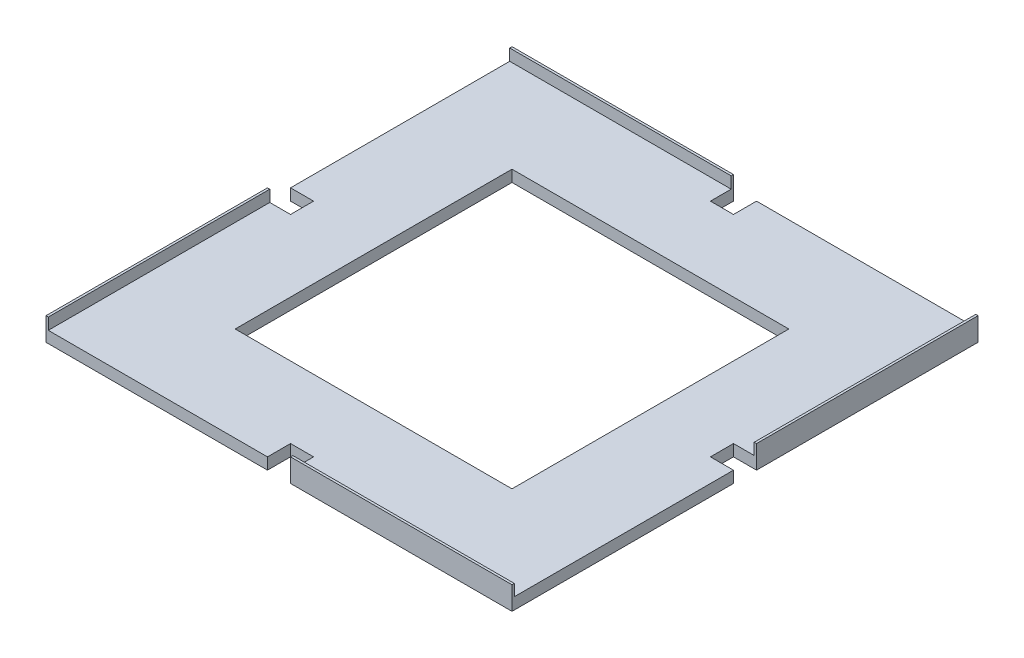
from build123d import *

# Parameters (mm, degrees)
SKETCH1_W           = 120
SKETCH1_H           = 120
BOSS_EXTRUDE1_DEPTH = 5
SKETCH2_W           = 96
SKETCH2_H           = 1
SKETCH2_W_2         = 1
SKETCH2_H_2         = 96
BOSS_EXTRUDE2_DEPTH = 5


with BuildPart() as part:
    # Sketch1 → Boss-Extrude1 (new body)
    with BuildSketch(Plane(origin=(0, 0, 0), x_dir=(1, 0, 0), z_dir=(0, 1, 0))):
        Polygon((101, -101), (5, -101), (5, -91), (-5, -91), (-5, -101), (-101, -101), (-101, -5), (-91, -5), (-91, 5), (-101, 5), (-101, 101), (-5, 101), (-5, 91), (5, 91), (5, 101), (101, 101), (101, 5), (91, 5), (91, -5), (101, -5), align=None)
        Rectangle(SKETCH1_W, SKETCH1_H, mode=Mode.SUBTRACT)
    extrude(amount=BOSS_EXTRUDE1_DEPTH)

    # Sketch2 → Boss-Extrude2 (add)
    with BuildSketch(Plane(origin=(0, 5, 0), x_dir=(1, 0, 0), z_dir=(0, 1, 0))):
        with Locations((53, -100.5)):
            Rectangle(SKETCH2_W, SKETCH2_H)
        with Locations((-100.5, -53)):
            Rectangle(SKETCH2_W_2, SKETCH2_H_2)
        with Locations((-53, 100.5)):
            Rectangle(SKETCH2_W, SKETCH2_H)
        with Locations((100.5, 53)):
            Rectangle(SKETCH2_W_2, SKETCH2_H_2)
    extrude(amount=BOSS_EXTRUDE2_DEPTH)


solid = part.part
